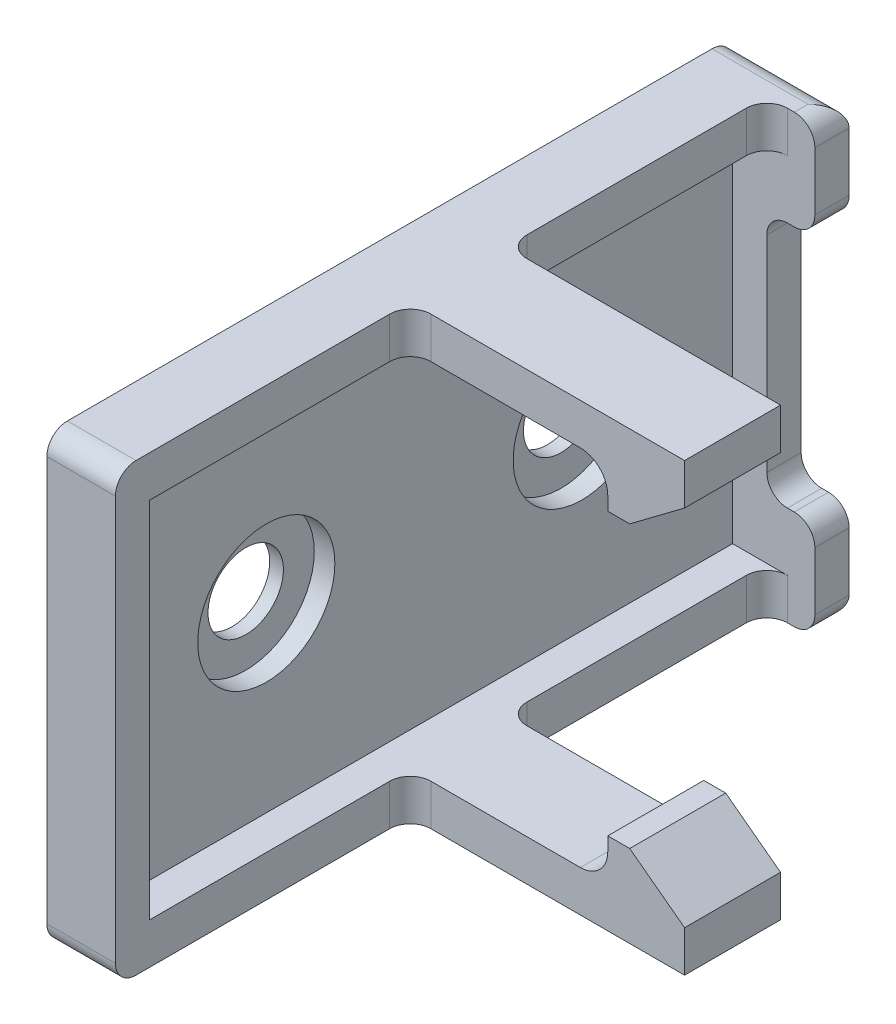
from build123d import *

# Parameters (mm, degrees)
SKETCH1_W           = 2.5
SKETCH1_H           = 32.5
BOSS_EXTRUDE1_DEPTH = 50
SKETCH5_R           = 2.75
CUT_EXTRUDE5_DEPTH  = 30.5
SKETCH6_R           = 5
CUT_EXTRUDE6_DEPTH  = 1.5
SKETCH7_W           = 50
SKETCH7_H           = 32.5
SKETCH7_W_2         = 45
SKETCH7_H_2         = 26.5
BOSS_EXTRUDE2_DEPTH = 2.5
SKETCH8_W           = 7
SKETCH8_H           = 6
BOSS_EXTRUDE3_DEPTH = 20
CUT_EXTRUDE9_DEPTH  = 20
SKETCH10_W          = 3.5
SKETCH10_H          = 7.25
BOSS_EXTRUDE4_DEPTH = 2.5
FILLET1_R           = 1.5


with BuildPart() as part:
    # Sketch1 → Boss-Extrude1 (new body)
    with BuildSketch(Plane.XY):
        Rectangle(SKETCH1_W, SKETCH1_H)
    extrude(amount=BOSS_EXTRUDE1_DEPTH)

    # Sketch5 → Cut-Extrude5 (cut)
    with BuildSketch(Plane.ZY.offset(1.25)):
        with Locations((13.5, 0)):
            Circle(SKETCH5_R)
        with Locations((36.5, 0)):
            Circle(SKETCH5_R)
    extrude(amount=-CUT_EXTRUDE5_DEPTH, mode=Mode.SUBTRACT)

    # Sketch6 → Cut-Extrude6 (cut)
    with BuildSketch(Plane(origin=(1.25, 0, 0), x_dir=(0, 0, -1), z_dir=(1, 0, 0))):
        with Locations((-36.5, 0)):
            Circle(SKETCH6_R)
        with Locations((-13.5, 0)):
            Circle(SKETCH6_R)
    extrude(amount=-CUT_EXTRUDE6_DEPTH, mode=Mode.SUBTRACT)

    # Sketch7 → Boss-Extrude2 (add)
    with BuildSketch(Plane(origin=(1.25, 0, 0), x_dir=(0, 0, -1), z_dir=(1, 0, 0))):
        with Locations((-25, 0)):
            Rectangle(SKETCH7_W, SKETCH7_H)
        with Locations((-25, 0)):
            Rectangle(SKETCH7_W_2, SKETCH7_H_2, mode=Mode.SUBTRACT)
    extrude(amount=BOSS_EXTRUDE2_DEPTH)

    # Sketch8 → Boss-Extrude3 (add)
    with BuildSketch(Plane(origin=(3.75, 0, 0), x_dir=(0, 0, -1), z_dir=(1, 0, 0))):
        with Locations((-25, 13.25)):
            Rectangle(SKETCH8_W, SKETCH8_H)
        with Locations((-25, -13.25)):
            Rectangle(SKETCH8_W, SKETCH8_H)
    extrude(amount=BOSS_EXTRUDE3_DEPTH)

    # Sketch9 → Cut-Extrude9 (cut)
    with BuildSketch(Plane(origin=(0, 0, 21.5), x_dir=(-1, 0, 0), z_dir=(0, 0, -1))):
        with BuildLine():
            Line((-3.75, 13.25), (-16.15, 13.25))
            ThreePointArc((-16.15, 13.25), (-17.564213562, 12.664213562), (-18.15, 11.25))
            Line((-18.15, 11.25), (-18.15, 10.25))
            Line((-18.15, 10.25), (-3.75, 10.25))
            Line((-3.75, 10.25), (-3.75, 13.25))
        make_face()
        with BuildLine():
            Line((-3.75, -10.25), (-3.75, -13.25))
            Line((-3.75, -13.25), (-16.15, -13.25))
            ThreePointArc((-16.15, -13.25), (-17.564213562, -12.664213562), (-18.15, -11.25))
            Line((-18.15, -11.25), (-18.15, -10.25))
            Line((-18.15, -10.25), (-3.75, -10.25))
        make_face()
        Polygon((-23.75, 13.25), (-19.75, 10.25), (-23.75, 10.25), align=None)
        Polygon((-23.75, -10.25), (-23.75, -13.25), (-19.75, -10.25), align=None)
    extrude(amount=-CUT_EXTRUDE9_DEPTH, mode=Mode.SUBTRACT)

    # Sketch10 → Boss-Extrude4 (add)
    with BuildSketch(Plane.XY.offset(2.5)):
        with Locations((5.5, -12.625)):
            Rectangle(SKETCH10_W, SKETCH10_H)
        with Locations((5.5, 12.625)):
            Rectangle(SKETCH10_W, SKETCH10_H)
    extrude(amount=-BOSS_EXTRUDE4_DEPTH)

    # Fillet1
    fillet1_edges = [part.edges().sort_by_distance(p)[0] for p in [
        (3, -16.25, 0),
        (3, 16.25, 0),
        (1.25, 16.25, 50),
        (1.25, -16.25, 50),
        (3.75, -14.75, 28.5),
        (3.75, 14.75, 28.5),
        (3.75, 14.75, 21.5),
        (3.75, -14.75, 21.5),
        (7.25, -16.25, 1.25),
        (3.75, -14.75, 2.5),
        (3.75, 14.75, 2.5),
        (7.25, 16.25, 1.25),
        (7.25, -9, 1.25),
        (3.75, -9, 1.25),
        (7.25, 9, 1.25),
        (3.75, 9, 1.25),
    ]]
    fillet(fillet1_edges, radius=FILLET1_R)


solid = part.part
